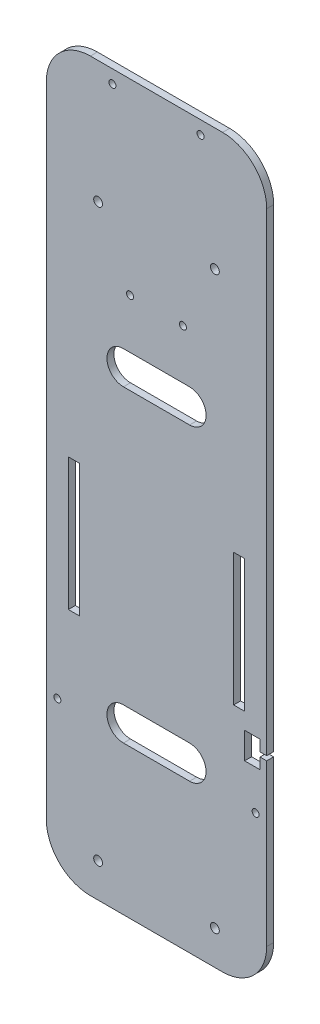
from build123d import *

# Parameters (mm, degrees)
SKETCH1_R           = 2
SKETCH1_R_2         = 1.5875
SKETCH1_W           = 5
SKETCH1_H           = 60
BOSS_EXTRUDE1_DEPTH = 1.5875
FILLET1_R           = 20


with BuildPart() as part:
    # Sketch1 → Boss-Extrude1 (new body, symmetric)
    with BuildSketch(Plane.XY):
        Polygon((-50, -145), (50, -145), (50, -52), (47, -52), (47, -57), (40, -57), (40, -45), (47, -45), (47, -50), (50, -50), (50, 185), (-50, 185), align=None)
        with Locations((-26.5, -129.5)):
            Circle(SKETCH1_R, mode=Mode.SUBTRACT)
        with Locations((-45, -75)):
            Circle(SKETCH1_R_2, mode=Mode.SUBTRACT)
        with BuildLine():
            Line((15, -77.5), (-15, -77.5))
            ThreePointArc((-15, -77.5), (-22.5, -70), (-15, -62.5))
            Line((-15, -62.5), (15, -62.5))
            ThreePointArc((15, -62.5), (22.5, -70), (15, -77.5))
        make_face(mode=Mode.SUBTRACT)
        with Locations((-37.5, -7.531680382)):
            Rectangle(SKETCH1_W, SKETCH1_H, mode=Mode.SUBTRACT)
        with Locations((26.5, -129.5)):
            Circle(SKETCH1_R, mode=Mode.SUBTRACT)
        with Locations((45, -75)):
            Circle(SKETCH1_R_2, mode=Mode.SUBTRACT)
        with Locations((37.5, -7.531680382)):
            Rectangle(SKETCH1_W, SKETCH1_H, mode=Mode.SUBTRACT)
        with BuildLine():
            ThreePointArc((-15, 62.5), (-22.5, 70), (-15, 77.5))
            Line((-15, 77.5), (15, 77.5))
            ThreePointArc((15, 77.5), (22.5, 70), (15, 62.5))
            Line((15, 62.5), (-15, 62.5))
        make_face(mode=Mode.SUBTRACT)
        with Locations((-12, 100)):
            Circle(SKETCH1_R_2, mode=Mode.SUBTRACT)
        with Locations((-26.5, 129.5)):
            Circle(SKETCH1_R, mode=Mode.SUBTRACT)
        with Locations((12, 100)):
            Circle(SKETCH1_R_2, mode=Mode.SUBTRACT)
        with Locations((26.5, 129.5)):
            Circle(SKETCH1_R, mode=Mode.SUBTRACT)
        with Locations((20, 179)):
            Circle(SKETCH1_R_2, mode=Mode.SUBTRACT)
        with Locations((-20, 179)):
            Circle(SKETCH1_R_2, mode=Mode.SUBTRACT)
    extrude(amount=BOSS_EXTRUDE1_DEPTH, both=True)

    # Fillet1
    fillet1_edges = [part.edges().sort_by_distance(p)[0] for p in [
        (-50, 185, 0),
        (50, 185, 0),
        (-50, -145, 0),
        (50, -145, 0),
    ]]
    fillet(fillet1_edges, radius=FILLET1_R)


solid = part.part
